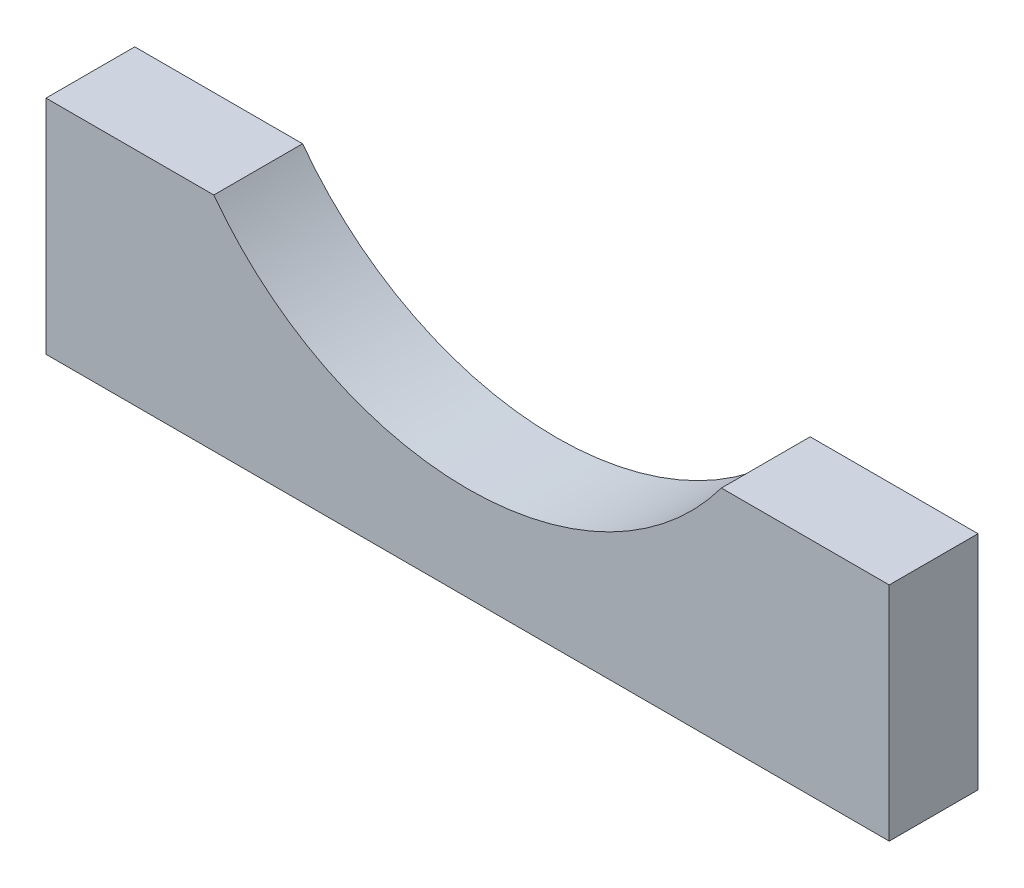
from build123d import *

# Parameters (mm, degrees)
SKETCH2_W           = 38
SKETCH2_H           = 10
BOSS_EXTRUDE2_DEPTH = 4
SKETCH3_R           = 14.25
CUT_EXTRUDE1_DEPTH  = 10


with BuildPart() as part:
    # Sketch2 → Boss-Extrude2 (new body)
    with BuildSketch(Plane.XY):
        with Locations((19, 5)):
            Rectangle(SKETCH2_W, SKETCH2_H)
    extrude(amount=BOSS_EXTRUDE2_DEPTH)

    # Sketch3 → Cut-Extrude1 (cut)
    with BuildSketch(Plane.XY.offset(4)):
        with Locations((19, 18.5)):
            Circle(SKETCH3_R)
    extrude(amount=-CUT_EXTRUDE1_DEPTH, mode=Mode.SUBTRACT)


solid = part.part
